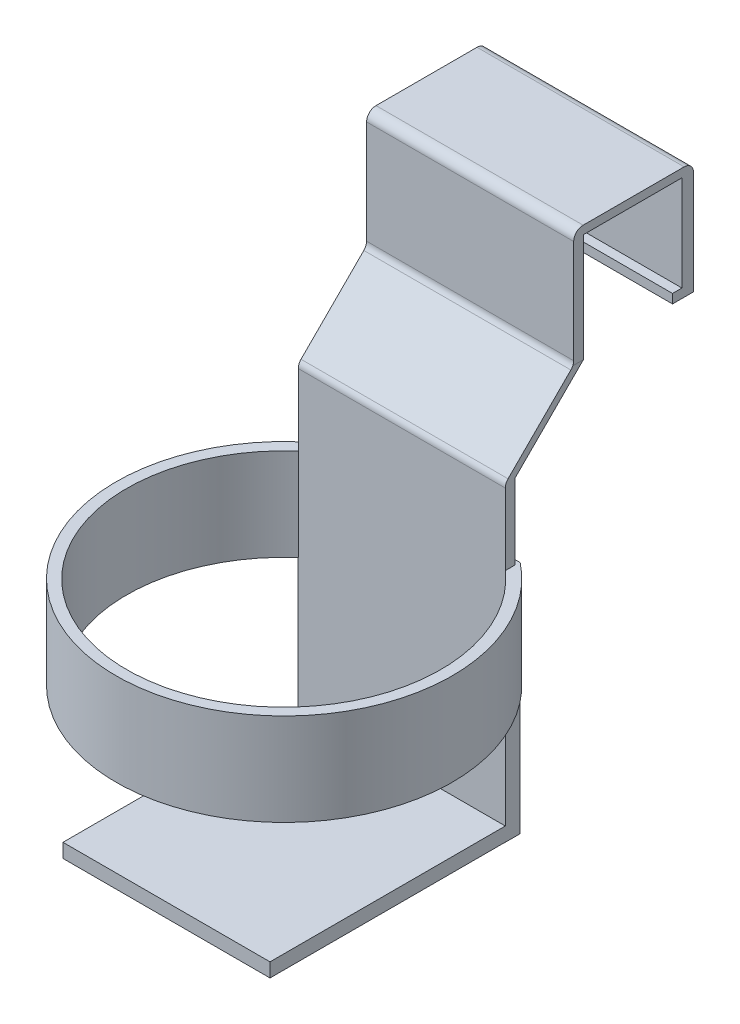
from build123d import *

# Parameters (mm, degrees)
SKETCH2_W            = 55.901800272
SKETCH2_H            = 3.137316852
BOSS_EXTRUDE1_DEPTH  = 36.83
SKETCH3_W            = 55.901800272
SKETCH3_H            = 2.258710987
BOSS_EXTRUDE2_DEPTH  = 29.21
SKETCH4_W            = 55.901800272
SKETCH4_H            = 2.656475696
BOSS_EXTRUDE3_DEPTH  = 29.21
BOSS_EXTRUDE4_DEPTH  = 55.88
SKETCH7_W            = 55.88
SKETCH7_H            = 2.656475696
BOSS_EXTRUDE5_DEPTH  = 83.82
SKETCH8_W            = 55.88
SKETCH8_H            = 3.77839036
BOSS_EXTRUDE6_DEPTH  = 63.5
SKETCH18_W           = 55.901800272
SKETCH18_H           = 2.413327827
BOSS_EXTRUDE9_DEPTH  = 3.81
SKETCH20_R           = 45.365929921
BOSS_EXTRUDE10_DEPTH = 59.69
CUT_EXTRUDE2_DEPTH   = 59.69
CUT_EXTRUDE4_DEPTH   = 59.69
SKETCH23_R           = 50.619817538
CUT_EXTRUDE5_DEPTH   = 34.798
SKETCH24_W           = 55.992252849
SKETCH24_H           = 3.903032237
BOSS_EXTRUDE11_DEPTH = 38.608
SKETCH25_W           = 55.901800272
SKETCH25_H           = 6.947316852
CUT_EXTRUDE6_DEPTH   = 6.35
SKETCH26_W           = 55.901800272
SKETCH26_H           = 2.460794709
BOSS_EXTRUDE12_DEPTH = 2.54
FILLET2_R            = 2.54
FILLET4_R            = 2.54
FILLET5_R            = 2.54


with BuildPart() as part:
    # Sketch2 → Boss-Extrude1 (new body)
    with BuildSketch(Plane(origin=(0, 0, 0), x_dir=(1, 0, 0), z_dir=(0, 1, 0))):
        with Locations((27.950900136, 1.568658426)):
            Rectangle(SKETCH2_W, SKETCH2_H)
    extrude(amount=BOSS_EXTRUDE1_DEPTH)

    # Sketch3 → Boss-Extrude2 (add)
    with BuildSketch(Plane.XY):
        with Locations((27.950900136, 35.700644507)):
            Rectangle(SKETCH3_W, SKETCH3_H)
    extrude(amount=BOSS_EXTRUDE2_DEPTH)

    # Sketch4 → Boss-Extrude3 (add)
    with BuildSketch(Plane.XZ.offset(-34.571289013)):
        with Locations((27.950900136, 27.881762152)):
            Rectangle(SKETCH4_W, SKETCH4_H)
    extrude(amount=BOSS_EXTRUDE3_DEPTH)

    # Sketch6 → Boss-Extrude4 (add)
    with BuildSketch(Plane.ZY):
        Polygon((29.21, 5.361289013), (29.21, 8.93281191), (29.21, 36.83), (-3.137316852, 36.83), (-3.137316852, 0), (0, 0), (0, 34.571289013), (26.553524304, 34.571289013), (26.553524304, 5.361289013), (44.996482377, -13.08166906), (47.652958073, -13.08166906), align=None)
    extrude(amount=-BOSS_EXTRUDE4_DEPTH)

    # Sketch7 → Boss-Extrude5 (add)
    with BuildSketch(Plane.XZ.offset(13.08166906)):
        with Locations((27.94, 46.324720225)):
            Rectangle(SKETCH7_W, SKETCH7_H)
    extrude(amount=BOSS_EXTRUDE5_DEPTH)

    # Sketch8 → Boss-Extrude6 (add)
    with BuildSketch(Plane.XY.offset(47.652958073)):
        with Locations((27.94, -95.01247388)):
            Rectangle(SKETCH8_W, SKETCH8_H)
    extrude(amount=BOSS_EXTRUDE6_DEPTH)

    # Sketch18 → Boss-Extrude9 (add)
    with BuildSketch(Plane.XY):
        with Locations((27.950900136, 1.206663914)):
            Rectangle(SKETCH18_W, SKETCH18_H)
    extrude(amount=BOSS_EXTRUDE9_DEPTH)

    # Sketch20 → Boss-Extrude10 (add)
    with BuildSketch(Plane(origin=(0, -93.1232787, 0), x_dir=(1, 0, 0), z_dir=(0, 1, 0))):
        with Locations((27.94, -79.402958073)):
            Circle(SKETCH20_R)
    extrude(amount=BOSS_EXTRUDE10_DEPTH)

    # Sketch21 → Cut-Extrude2 (cut)
    with BuildSketch(Plane(origin=(0, -33.4332787, 0), x_dir=(1, 0, 0), z_dir=(0, 1, 0))):
        with BuildLine():
            Line((55.88, -47.652958073), (0, -47.652958073))
            ThreePointArc((0, -47.652958073), (27.94, -121.892938161), (55.88, -47.652958073))
        make_face()
    extrude(amount=-CUT_EXTRUDE2_DEPTH, mode=Mode.SUBTRACT)

    # Sketch22 → Cut-Extrude4 (cut)
    with BuildSketch(Plane(origin=(0, -33.4332787, 0), x_dir=(1, 0, 0), z_dir=(0, 1, 0))):
        Polygon((-0.112252849, -43.749925836), (55.992252849, -43.749925836), (52.485687981, -29.879615978), (-0.112252849, -30.827478948), align=None)
    extrude(amount=-CUT_EXTRUDE4_DEPTH, mode=Mode.SUBTRACT)

    # Sketch23 → Cut-Extrude5 (cut)
    with BuildSketch(Plane.XZ.offset(93.1232787)):
        with Locations((27.94, 84.259406915)):
            Circle(SKETCH23_R)
    extrude(amount=-CUT_EXTRUDE5_DEPTH, mode=Mode.SUBTRACT)

    # Sketch24 → Boss-Extrude11 (add)
    with BuildSketch(Plane.XZ.offset(58.3252787)):
        with Locations((27.883873576, 45.701441954)):
            Rectangle(SKETCH24_W, SKETCH24_H)
    extrude(amount=BOSS_EXTRUDE11_DEPTH)

    # Sketch25 → Cut-Extrude6 (cut)
    with BuildSketch(Plane.XZ):
        with Locations((27.950900136, 0.336341574)):
            Rectangle(SKETCH25_W, SKETCH25_H)
    extrude(amount=-CUT_EXTRUDE6_DEPTH, mode=Mode.SUBTRACT)

    # Sketch26 → Boss-Extrude12 (add)
    with BuildSketch(Plane.XY):
        with Locations((27.950900136, 7.580397355)):
            Rectangle(SKETCH26_W, SKETCH26_H)
    extrude(amount=BOSS_EXTRUDE12_DEPTH)

    # Fillet2
    fillet2_edges = [part.edges().sort_by_distance(p)[0] for p in [
        (27.950900136, 36.83, -3.137316852),
        (27.950900136, 36.83, 29.21),
    ]]
    fillet(fillet2_edges, radius=FILLET2_R)

    # Fillet4
    fillet4_edges = [part.edges().sort_by_distance(p)[0] for p in [
        (27.94, 5.361289013, 29.21),
    ]]
    fillet(fillet4_edges, radius=FILLET4_R)

    # Fillet5
    fillet5_edges = [part.edges().sort_by_distance(p)[0] for p in [
        (27.94, -13.08166906, 47.652958073),
    ]]
    fillet(fillet5_edges, radius=FILLET5_R)


solid = part.part
